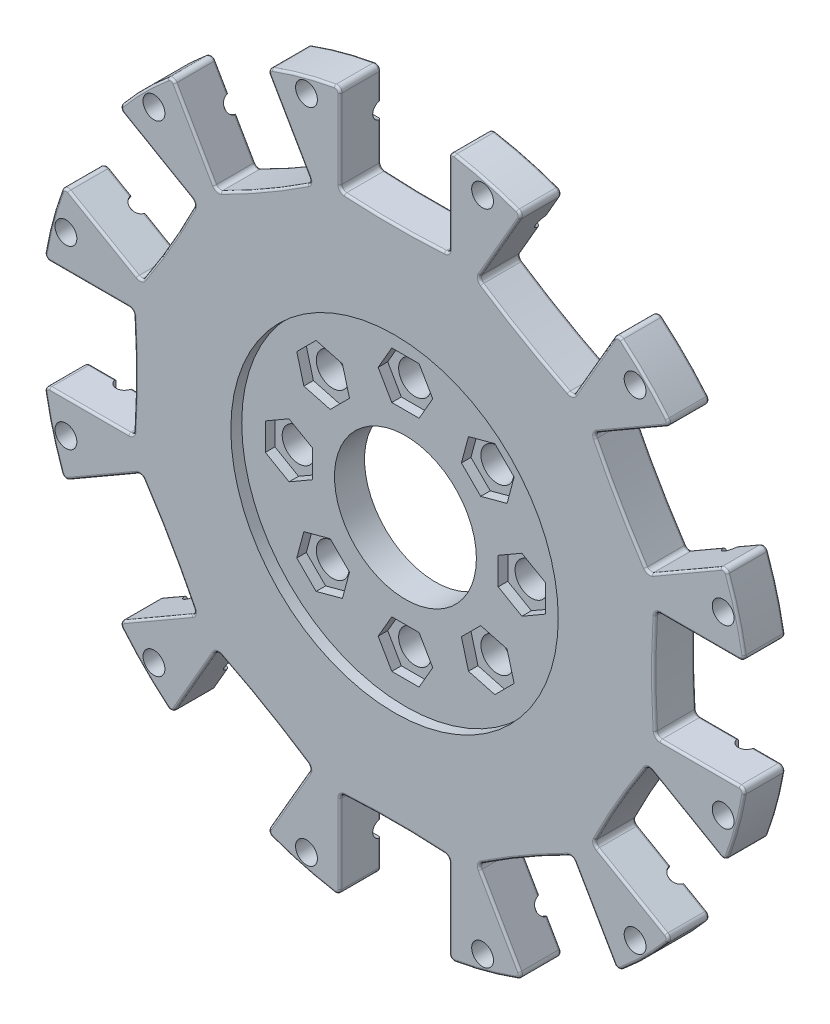
from build123d import *

# Parameters (mm, degrees)
BOSS_EXTRUDE1_DEPTH = 7.5
CUT_EXTRUDE1_DEPTH  = 3.75
SKETCH3_3_R         = 13
SKETCH3_3_R_2       = 2
SKETCH3_3_R_3       = 3
CUT_EXTRUDE2_DEPTH  = 92.138630668
SKETCH3_4_R         = 30
CUT_EXTRUDE3_DEPTH  = 2
SKETCH8_W           = 24
SKETCH8_H           = 1.5
CIRPATTERN1_COUNT   = 12
FILLET1_R           = 0.9
FILLET2_R           = 0.4


with BuildPart() as part:
    # Sketch2 → Boss-Extrude1 (new body)
    with BuildSketch(Plane.XY):
        with BuildLine():
            Line((-10, 47.833704529), (-10, 64.226162893))
            ThreePointArc((-10, 64.226162893), (-16.823237932, 62.785178709), (-23.452827409, 60.621488653))
            Line((-23.452827409, 60.621488653), (-15.256598227, 46.425203279))
            ThreePointArc((-15.256598227, 46.425203279), (-23.75, 41.13620668), (-32.577106302, 36.425203279))
            Line((-32.577106302, 36.425203279), (-40.773335485, 50.621488653))
            ThreePointArc((-40.773335485, 50.621488653), (-45.961940777, 45.961940777), (-50.621488653, 40.773335485))
            Line((-50.621488653, 40.773335485), (-36.425203279, 32.577106302))
            ThreePointArc((-36.425203279, 32.577106302), (-41.13620668, 23.75), (-46.425203279, 15.256598227))
            Line((-46.425203279, 15.256598227), (-60.621488653, 23.452827409))
            ThreePointArc((-60.621488653, 23.452827409), (-62.785178709, 16.823237932), (-64.226162893, 10))
            Line((-64.226162893, 10), (-47.833704529, 10))
            ThreePointArc((-47.833704529, 10), (-47.5, 0), (-47.833704529, -10))
            Line((-47.833704529, -10), (-64.226162893, -10))
            ThreePointArc((-64.226162893, -10), (-62.785178709, -16.823237932), (-60.621488653, -23.452827409))
            Line((-60.621488653, -23.452827409), (-46.425203279, -15.256598227))
            ThreePointArc((-46.425203279, -15.256598227), (-41.13620668, -23.75), (-36.425203279, -32.577106302))
            Line((-36.425203279, -32.577106302), (-50.621488653, -40.773335485))
            ThreePointArc((-50.621488653, -40.773335485), (-45.961940777, -45.961940777), (-40.773335485, -50.621488653))
            Line((-40.773335485, -50.621488653), (-32.577106302, -36.425203279))
            ThreePointArc((-32.577106302, -36.425203279), (-23.75, -41.13620668), (-15.256598227, -46.425203279))
            Line((-15.256598227, -46.425203279), (-23.452827409, -60.621488653))
            ThreePointArc((-23.452827409, -60.621488653), (-16.823237932, -62.785178709), (-10, -64.226162893))
            Line((-10, -64.226162893), (-10, -47.833704529))
            ThreePointArc((-10, -47.833704529), (0, -47.5), (10, -47.833704529))
            Line((10, -47.833704529), (10, -64.226162893))
            ThreePointArc((10, -64.226162893), (16.823237932, -62.785178709), (23.452827409, -60.621488653))
            Line((23.452827409, -60.621488653), (15.256598227, -46.425203279))
            ThreePointArc((15.256598227, -46.425203279), (23.75, -41.13620668), (32.577106302, -36.425203279))
            Line((32.577106302, -36.425203279), (40.773335485, -50.621488653))
            ThreePointArc((40.773335485, -50.621488653), (45.961940777, -45.961940777), (50.621488653, -40.773335485))
            Line((50.621488653, -40.773335485), (36.425203279, -32.577106302))
            ThreePointArc((36.425203279, -32.577106302), (41.13620668, -23.75), (46.425203279, -15.256598227))
            Line((46.425203279, -15.256598227), (60.621488653, -23.452827409))
            ThreePointArc((60.621488653, -23.452827409), (62.785178709, -16.823237932), (64.226162893, -10))
            Line((64.226162893, -10), (47.833704529, -10))
            ThreePointArc((47.833704529, -10), (47.5, 0), (47.833704529, 10))
            Line((47.833704529, 10), (64.226162893, 10))
            ThreePointArc((64.226162893, 10), (62.785178709, 16.823237932), (60.621488653, 23.452827409))
            Line((60.621488653, 23.452827409), (46.425203279, 15.256598227))
            ThreePointArc((46.425203279, 15.256598227), (41.13620668, 23.75), (36.425203279, 32.577106302))
            Line((36.425203279, 32.577106302), (50.621488653, 40.773335485))
            ThreePointArc((50.621488653, 40.773335485), (45.961940777, 45.961940777), (40.773335485, 50.621488653))
            Line((40.773335485, 50.621488653), (32.577106302, 36.425203279))
            ThreePointArc((32.577106302, 36.425203279), (23.75, 41.13620668), (15.256598227, 46.425203279))
            Line((15.256598227, 46.425203279), (23.452827409, 60.621488653))
            ThreePointArc((23.452827409, 60.621488653), (16.823237932, 62.785178709), (10, 64.226162893))
            Line((10, 64.226162893), (10, 47.833704529))
            ThreePointArc((10, 47.833704529), (0, 47.5), (-10, 47.833704529))
        make_face()
    extrude(amount=BOSS_EXTRUDE1_DEPTH)

    # Sketch3 → Cut-Extrude1 (cut)
    with BuildSketch(Plane.XY.offset(7.5)):
        Polygon((18.619374826, 11.548307015), (19.913470052, 16.377936146), (16.377936146, 19.913470052), (11.548307015, 18.619374826), (10.254211789, 13.789745695), (13.789745695, 10.254211789), align=None)
        Polygon((5, 21.331772403), (2.5, 25.661899421), (-2.5, 25.661899421), (-5, 21.331772403), (-2.5, 17.001645384), (2.5, 17.001645384), align=None)
        Polygon((21.331772403, -5), (25.661899421, -2.5), (25.661899421, 2.5), (21.331772403, 5), (17.001645384, 2.5), (17.001645384, -2.5), align=None)
        Polygon((11.548307015, -18.619374826), (16.377936146, -19.913470052), (19.913470052, -16.377936146), (18.619374826, -11.548307015), (13.789745695, -10.254211789), (10.254211789, -13.789745695), align=None)
        Polygon((-5, -21.331772403), (-2.5, -25.661899421), (2.5, -25.661899421), (5, -21.331772403), (2.5, -17.001645384), (-2.5, -17.001645384), align=None)
        Polygon((-18.619374826, -11.548307015), (-19.913470052, -16.377936146), (-16.377936146, -19.913470052), (-11.548307015, -18.619374826), (-10.254211789, -13.789745695), (-13.789745695, -10.254211789), align=None)
        Polygon((-21.331772403, 5), (-25.661899421, 2.5), (-25.661899421, -2.5), (-21.331772403, -5), (-17.001645384, -2.5), (-17.001645384, 2.5), align=None)
        Polygon((-11.548307015, 18.619374826), (-16.377936146, 19.913470052), (-19.913470052, 16.377936146), (-18.619374826, 11.548307015), (-13.789745695, 10.254211789), (-10.254211789, 13.789745695), align=None)
    extrude(amount=-CUT_EXTRUDE1_DEPTH, mode=Mode.SUBTRACT)

    # Sketch3_3 → Cut-Extrude2 (cut, through all)
    with BuildSketch(Plane.XY.offset(7.5)):
        Circle(SKETCH3_3_R)
        with Locations((44.07976206, 44.07976206)):
            Circle(SKETCH3_3_R_2)
        with Locations((60.214074767, 16.134312707)):
            Circle(SKETCH3_3_R_2)
        with Locations((60.214074767, -16.134312707)):
            Circle(SKETCH3_3_R_2)
        with Locations((44.07976206, -44.07976206)):
            Circle(SKETCH3_3_R_2)
        with Locations((16.134312707, -60.214074767)):
            Circle(SKETCH3_3_R_2)
        with Locations((-16.134312707, -60.214074767)):
            Circle(SKETCH3_3_R_2)
        with Locations((-44.07976206, -44.07976206)):
            Circle(SKETCH3_3_R_2)
        with Locations((-60.214074767, -16.134312707)):
            Circle(SKETCH3_3_R_2)
        with Locations((-60.214074767, 16.134312707)):
            Circle(SKETCH3_3_R_2)
        with Locations((-44.07976206, 44.07976206)):
            Circle(SKETCH3_3_R_2)
        with Locations((-16.134312707, 60.214074767)):
            Circle(SKETCH3_3_R_2)
        with Locations((16.134312707, 60.214074767)):
            Circle(SKETCH3_3_R_2)
        with Locations((0, 21.331772403)):
            Circle(SKETCH3_3_R_3)
        with Locations((15.083840921, 15.083840921)):
            Circle(SKETCH3_3_R_3)
        with Locations((21.331772403, 0)):
            Circle(SKETCH3_3_R_3)
        with Locations((15.083840921, -15.083840921)):
            Circle(SKETCH3_3_R_3)
        with Locations((0, -21.331772403)):
            Circle(SKETCH3_3_R_3)
        with Locations((-15.083840921, -15.083840921)):
            Circle(SKETCH3_3_R_3)
        with Locations((-21.331772403, 0)):
            Circle(SKETCH3_3_R_3)
        with Locations((-15.083840921, 15.083840921)):
            Circle(SKETCH3_3_R_3)
    extrude(amount=-CUT_EXTRUDE2_DEPTH, mode=Mode.SUBTRACT)

    # Sketch3_4 → Cut-Extrude3 (cut)
    with BuildSketch(Plane.XY.offset(7.5)):
        Circle(SKETCH3_4_R)
    extrude(amount=-CUT_EXTRUDE3_DEPTH, mode=Mode.SUBTRACT)

    # Sketch8 → Cut-Revolve2 (revolve, cut)
    with BuildSketch(Plane(origin=(0, 0, 0), x_dir=(-1, 0, 0), z_dir=(0, 0, -1))):
        with Locations((0, 57.75)):
            Rectangle(SKETCH8_W, SKETCH8_H)
    cut_revolve2 = revolve(axis=Axis((12, 57, 0), (-1, 0, 0)), mode=Mode.SUBTRACT)

    # CirPattern1: Cut-Revolve2 ×12 about axis
    cirpattern1_axis = Axis((0, 0, 0), (0, 0, 1))
    for i in range(1, CIRPATTERN1_COUNT):
        add(cut_revolve2.rotate(cirpattern1_axis, i * 360 / CIRPATTERN1_COUNT), mode=Mode.SUBTRACT)

    # Fillet1
    fillet1_edges = [part.edges().sort_by_distance(p)[0] for p in [
        (64.226162893, -10, 3.75),
        (60.621488653, -23.452827409, 3.75),
        (46.425203279, -15.256598227, 3.75),
        (36.425203279, -32.577106302, 3.75),
        (50.621488653, -40.773335485, 3.75),
        (40.773335485, -50.621488653, 3.75),
        (32.577106302, -36.425203279, 3.75),
        (15.256598227, -46.425203279, 3.75),
        (23.452827409, -60.621488653, 3.75),
        (10, -64.226162893, 3.75),
        (10, -47.833704529, 3.75),
        (-10, -47.833704529, 3.75),
        (-10, -64.226162893, 3.75),
        (-23.452827409, -60.621488653, 3.75),
        (-15.256598227, -46.425203279, 3.75),
        (-32.577106302, -36.425203279, 3.75),
        (-40.773335485, -50.621488653, 3.75),
        (-50.621488653, -40.773335485, 3.75),
        (-36.425203279, -32.577106302, 3.75),
        (-46.425203279, -15.256598227, 3.75),
        (-60.621488653, -23.452827409, 3.75),
        (-64.226162893, -10, 3.75),
        (-47.833704529, -10, 3.75),
        (-47.833704529, 10, 3.75),
        (-64.226162893, 10, 3.75),
        (-60.621488653, 23.452827409, 3.75),
        (-46.425203279, 15.256598227, 3.75),
        (-36.425203279, 32.577106302, 3.75),
        (-50.621488653, 40.773335485, 3.75),
        (-40.773335485, 50.621488653, 3.75),
        (-32.577106302, 36.425203279, 3.75),
        (-15.256598227, 46.425203279, 3.75),
        (-23.452827409, 60.621488653, 3.75),
        (-10, 64.226162893, 3.75),
        (-10, 47.833704529, 3.75),
        (10, 47.833704529, 3.75),
        (10, 64.226162893, 3.75),
        (23.452827409, 60.621488653, 3.75),
        (15.256598227, 46.425203279, 3.75),
        (32.577106302, 36.425203279, 3.75),
        (40.773335485, 50.621488653, 3.75),
        (36.425203279, 32.577106302, 3.75),
        (46.425203279, 15.256598227, 3.75),
        (60.621488653, 23.452827409, 3.75),
        (64.226162893, 10, 3.75),
        (47.833704529, 10, 3.75),
        (47.833704529, -10, 3.75),
        (50.621488653, 40.773335485, 3.75),
    ]]
    fillet(fillet1_edges, radius=FILLET1_R)

    # Fillet2
    fillet2_edges = [part.edges().sort_by_distance(p)[0] for p in [
        (48.061288783, -9.755529031, 0),
        (48.061288783, 9.755529031, 0),
        (63.854828192, 10.320231904, 0),
        (60.46001932, 22.989831094, 0),
        (46.50006154, 15.582108424, 0),
        (36.744532509, 32.479180359, 0),
        (32.479180359, 36.744532509, 0),
        (15.582108424, 46.50006154, 0),
        (22.989831094, 60.46001932, 0),
        (10.320231904, 63.854828192, 0),
        (9.755529031, 48.061288783, 0),
        (-9.755529031, 48.061288783, 0),
        (-10.320231904, 63.854828192, 0),
        (-22.989831094, 60.46001932, 0),
        (-15.582108424, 46.50006154, 0),
        (-32.479180359, 36.744532509, 0),
        (-40.864997097, 50.139787416, 0),
        (-50.139787416, 40.864997097, 0),
        (-36.744532509, 32.479180359, 0),
        (-46.50006154, 15.582108424, 0),
        (-60.46001932, 22.989831094, 0),
        (-63.854828192, 10.320231904, 0),
        (-48.061288783, 9.755529031, 0),
        (-48.061288783, -9.755529031, 0),
        (-63.854828192, -10.320231904, 0),
        (-60.46001932, -22.989831094, 0),
        (-46.50006154, -15.582108424, 0),
        (-36.744532509, -32.479180359, 0),
        (-50.139787416, -40.864997097, 0),
        (-40.864997097, -50.139787416, 0),
        (-32.479180359, -36.744532509, 0),
        (-15.582108424, -46.50006154, 0),
        (-22.989831094, -60.46001932, 0),
        (-10.320231904, -63.854828192, 0),
        (-9.755529031, -48.061288783, 0),
        (9.755529031, -48.061288783, 0),
        (10.320231904, -63.854828192, 0),
        (22.989831094, -60.46001932, 0),
        (15.582108424, -46.50006154, 0),
        (32.479180359, -36.744532509, 0),
        (40.864997097, -50.139787416, 0),
        (50.139787416, -40.864997097, 0),
        (36.744532509, -32.479180359, 0),
        (46.50006154, -15.582108424, 0),
        (60.46001932, -22.989831094, 0),
        (63.854828192, -10.320231904, 0),
        (60.46001932, -22.989831094, 7.5),
        (46.50006154, -15.582108424, 7.5),
        (36.744532509, -32.479180359, 7.5),
        (50.139787416, -40.864997097, 7.5),
        (40.864997097, -50.139787416, 7.5),
        (32.479180359, -36.744532509, 7.5),
        (15.582108424, -46.50006154, 7.5),
        (22.989831094, -60.46001932, 7.5),
        (10.320231904, -63.854828192, 7.5),
        (9.755529031, -48.061288783, 7.5),
        (-9.755529031, -48.061288783, 7.5),
        (-10.320231904, -63.854828192, 7.5),
        (-22.989831094, -60.46001932, 7.5),
        (-15.582108424, -46.50006154, 7.5),
        (-32.479180359, -36.744532509, 7.5),
        (-40.864997097, -50.139787416, 7.5),
        (-50.139787416, -40.864997097, 7.5),
        (-36.744532509, -32.479180359, 7.5),
        (-46.50006154, -15.582108424, 7.5),
        (-60.46001932, -22.989831094, 7.5),
        (-63.854828192, -10.320231904, 7.5),
        (-48.061288783, -9.755529031, 7.5),
        (-48.061288783, 9.755529031, 7.5),
        (-63.854828192, 10.320231904, 7.5),
        (-60.46001932, 22.989831094, 7.5),
        (-46.50006154, 15.582108424, 7.5),
        (-36.744532509, 32.479180359, 7.5),
        (-50.139787416, 40.864997097, 7.5),
        (-40.864997097, 50.139787416, 7.5),
        (-32.479180359, 36.744532509, 7.5),
        (-15.582108424, 46.50006154, 7.5),
        (-22.989831094, 60.46001932, 7.5),
        (-10.320231904, 63.854828192, 7.5),
        (-9.755529031, 48.061288783, 7.5),
        (9.755529031, 48.061288783, 7.5),
        (10.320231904, 63.854828192, 7.5),
        (22.989831094, 60.46001932, 7.5),
        (15.582108424, 46.50006154, 7.5),
        (32.479180359, 36.744532509, 7.5),
        (40.864997097, 50.139787416, 7.5),
        (50.139787416, 40.864997097, 7.5),
        (36.744532509, 32.479180359, 7.5),
        (46.50006154, 15.582108424, 7.5),
        (60.46001932, 22.989831094, 7.5),
        (63.854828192, 10.320231904, 7.5),
        (48.061288783, 9.755529031, 7.5),
        (48.061288783, -9.755529031, 7.5),
        (63.854828192, -10.320231904, 7.5),
        (50.139787416, 40.864997097, 0),
        (40.864997097, 50.139787416, 0),
        (52.088979311, -10, 0),
        (60.833223395, -10, 0),
        (47.5, 0, 0),
        (52.088979311, 10, 0),
        (60.833223395, 10, 0),
        (62.785178709, 16.823237932, 0),
        (50.11037934, 17.384235618, 0),
        (57.683116854, 21.75635766, 0),
        (41.13620668, 23.75, 0),
        (40.11037934, 34.704743693, 0),
        (47.683116854, 39.076865735, 0),
        (34.704743693, 40.11037934, 0),
        (39.076865735, 47.683116854, 0),
        (23.75, 41.13620668, 0),
        (17.384235618, 50.11037934, 0),
        (21.75635766, 57.683116854, 0),
        (16.823237932, 62.785178709, 0),
        (10, 52.088979311, 0),
        (10, 60.833223395, 0),
        (0, 47.5, 0),
        (-10, 52.088979311, 0),
        (-10, 60.833223395, 0),
        (-16.823237932, 62.785178709, 0),
        (-17.384235618, 50.11037934, 0),
        (-21.75635766, 57.683116854, 0),
        (-23.75, 41.13620668, 0),
        (-34.704743693, 40.11037934, 0),
        (-39.076865735, 47.683116854, 0),
        (-45.961940777, 45.961940777, 0),
        (-40.11037934, 34.704743693, 0),
        (-47.683116854, 39.076865735, 0),
        (-41.13620668, 23.75, 0),
        (-50.11037934, 17.384235618, 0),
        (-57.683116854, 21.75635766, 0),
        (-62.785178709, 16.823237932, 0),
        (-52.088979311, 10, 0),
        (-60.833223395, 10, 0),
        (-47.5, 0, 0),
        (-52.088979311, -10, 0),
        (-60.833223395, -10, 0),
        (-62.785178709, -16.823237932, 0),
        (-50.11037934, -17.384235618, 0),
        (-57.683116854, -21.75635766, 0),
        (-41.13620668, -23.75, 0),
        (-40.11037934, -34.704743693, 0),
        (-47.683116854, -39.076865735, 0),
        (-45.961940777, -45.961940777, 0),
        (-34.704743693, -40.11037934, 0),
        (-39.076865735, -47.683116854, 0),
        (-23.75, -41.13620668, 0),
        (-17.384235618, -50.11037934, 0),
        (-21.75635766, -57.683116854, 0),
        (-16.823237932, -62.785178709, 0),
        (-10, -52.088979311, 0),
        (-10, -60.833223395, 0),
        (0, -47.5, 0),
        (10, -52.088979311, 0),
        (10, -60.833223395, 0),
        (16.823237932, -62.785178709, 0),
        (17.384235618, -50.11037934, 0),
        (21.75635766, -57.683116854, 0),
        (23.75, -41.13620668, 0),
        (34.704743693, -40.11037934, 0),
        (39.076865735, -47.683116854, 0),
        (45.961940777, -45.961940777, 0),
        (40.11037934, -34.704743693, 0),
        (47.683116854, -39.076865735, 0),
        (41.13620668, -23.75, 0),
        (50.11037934, -17.384235618, 0),
        (57.683116854, -21.75635766, 0),
        (62.785178709, -16.823237932, 0),
        (55.922202706, -10, 7.5),
        (47.5, 0, 7.5),
        (55.922202706, 10, 7.5),
        (62.785178709, 16.823237932, 7.5),
        (53.430048179, 19.300847315, 7.5),
        (41.13620668, 23.75, 7.5),
        (43.430048179, 36.621355391, 7.5),
        (45.961940777, 45.961940777, 7.5),
        (36.621355391, 43.430048179, 7.5),
        (23.75, 41.13620668, 7.5),
        (19.300847315, 53.430048179, 7.5),
        (16.823237932, 62.785178709, 7.5),
        (10, 55.922202706, 7.5),
        (0, 47.5, 7.5),
        (-10, 55.922202706, 7.5),
        (-16.823237932, 62.785178709, 7.5),
        (-19.300847315, 53.430048179, 7.5),
        (-23.75, 41.13620668, 7.5),
        (-36.621355391, 43.430048179, 7.5),
        (-45.961940777, 45.961940777, 7.5),
        (-43.430048179, 36.621355391, 7.5),
        (-41.13620668, 23.75, 7.5),
        (-53.430048179, 19.300847315, 7.5),
        (-62.785178709, 16.823237932, 7.5),
        (-55.922202706, 10, 7.5),
        (-47.5, 0, 7.5),
        (-55.922202706, -10, 7.5),
        (-62.785178709, -16.823237932, 7.5),
        (-53.430048179, -19.300847315, 7.5),
        (-41.13620668, -23.75, 7.5),
        (-43.430048179, -36.621355391, 7.5),
        (-45.961940777, -45.961940777, 7.5),
        (-36.621355391, -43.430048179, 7.5),
        (-23.75, -41.13620668, 7.5),
        (-19.300847315, -53.430048179, 7.5),
        (-16.823237932, -62.785178709, 7.5),
        (-10, -55.922202706, 7.5),
        (0, -47.5, 7.5),
        (10, -55.922202706, 7.5),
        (16.823237932, -62.785178709, 7.5),
        (19.300847315, -53.430048179, 7.5),
        (23.75, -41.13620668, 7.5),
        (36.621355391, -43.430048179, 7.5),
        (45.961940777, -45.961940777, 7.5),
        (43.430048179, -36.621355391, 7.5),
        (41.13620668, -23.75, 7.5),
        (53.430048179, -19.300847315, 7.5),
        (62.785178709, -16.823237932, 7.5),
        (45.961940777, 45.961940777, 0),
    ]]
    fillet(fillet2_edges, radius=FILLET2_R)


solid = part.part
